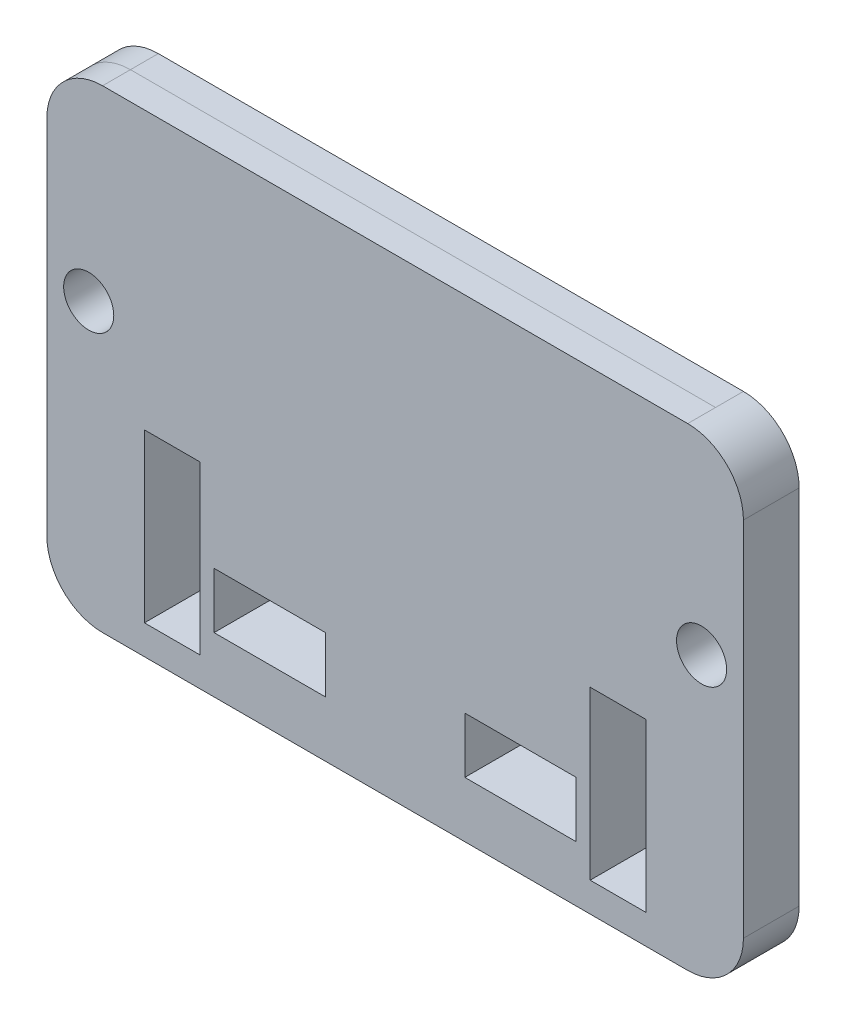
from build123d import *

# Parameters (mm, degrees)
SKETCH1_R                      = 11.422
BOSS_EXTRUDE1_DEPTH            = 25.4
SKETCH2_W                      = 50.8
SKETCH2_H                      = 25.4
FOAM_INSERT_CUT_THROUGHS_DEPTH = 25.4
SKETCH3_W                      = 25.4
SKETCH3_H                      = 76.2
CUT_EXTRUDE1_DEPTH             = 25.4


with BuildPart() as part:
    # Sketch1 → Boss-Extrude1 (new body)
    with BuildSketch(Plane.XY):
        with BuildLine():
            Line((-133.373251541, -107.95), (133.373251541, -107.95))
            ThreePointArc((133.373251541, -107.95), (151.333763783, -100.510512242), (158.773251541, -82.55))
            Line((158.773251541, -82.55), (158.773251541, 82.55))
            ThreePointArc((158.773251541, 82.55), (151.333763783, 100.510512242), (133.373251541, 107.95))
            Line((133.373251541, 107.95), (-133.373251541, 107.95))
            ThreePointArc((-133.373251541, 107.95), (-151.333763783, 100.510512242), (-158.773251541, 82.55))
            Line((-158.773251541, 82.55), (-158.773251541, -82.55))
            ThreePointArc((-158.773251541, -82.55), (-151.333763783, -100.510512242), (-133.373251541, -107.95))
        make_face()
        with Locations((-139.7, 19.739923182)):
            Circle(SKETCH1_R, mode=Mode.SUBTRACT)
        with Locations((139.7, 19.739923182)):
            Circle(SKETCH1_R, mode=Mode.SUBTRACT)
    extrude(amount=BOSS_EXTRUDE1_DEPTH)

    # Sketch2 → Foam Insert Cut-Throughs (cut)
    with BuildSketch(Plane(origin=(0, 0, 0), x_dir=(-1, 0, 0), z_dir=(0, 0, -1))):
        with Locations((-57.15, -69.85)):
            Rectangle(SKETCH2_W, SKETCH2_H)
        with Locations((57.15, -69.85)):
            Rectangle(SKETCH2_W, SKETCH2_H)
    extrude(amount=-FOAM_INSERT_CUT_THROUGHS_DEPTH, mode=Mode.SUBTRACT)

    # Sketch3 → Cut-Extrude1 (cut)
    with BuildSketch(Plane(origin=(0, 0, 0), x_dir=(-1, 0, 0), z_dir=(0, 0, -1))):
        with Locations((101.6, -56.460076818)):
            Rectangle(SKETCH3_W, SKETCH3_H)
        with Locations((-101.6, -56.460076818)):
            Rectangle(SKETCH3_W, SKETCH3_H)
    extrude(amount=-CUT_EXTRUDE1_DEPTH, mode=Mode.SUBTRACT)


solid = part.part
